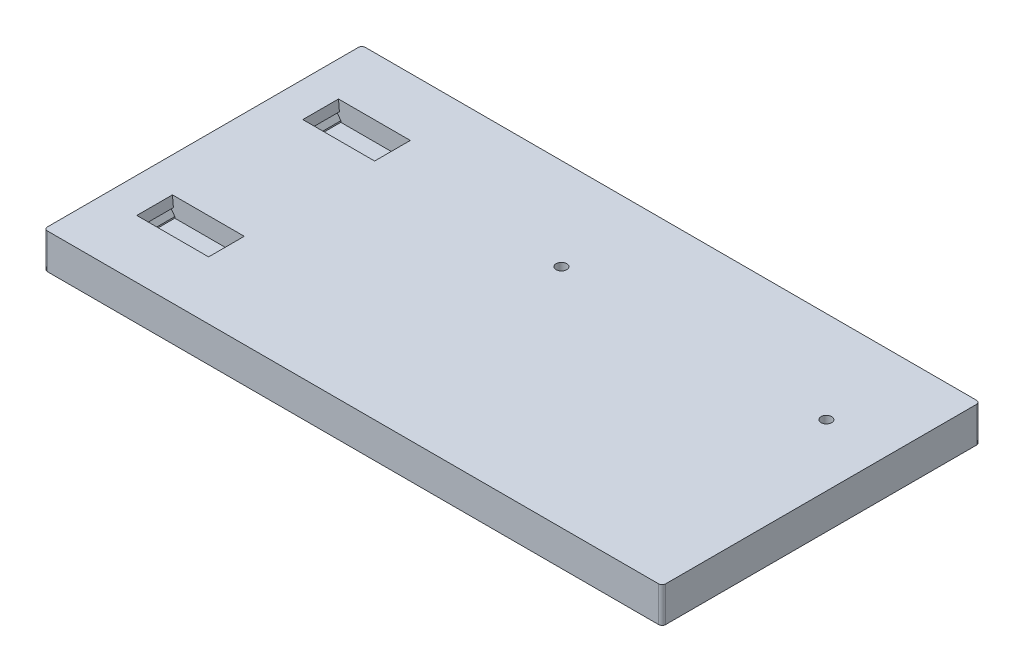
from build123d import *

# Parameters (mm, degrees)
SKETCH1_W           = 175
SKETCH1_H           = 90
BOSS_EXTRUDE1_DEPTH = 10
SKETCH2_W           = 19
SKETCH2_H           = 10.1
CUT_EXTRUDE1_DEPTH  = 5.4
CUT_EXTRUDE2_DEPTH  = 10.1
FILLET1_R           = 1
SKETCH2_8_R         = 1.5
CUT_EXTRUDE3_DEPTH  = 11


with BuildPart() as part:
    # Sketch1 → Boss-Extrude1 (new body)
    with BuildSketch(Plane(origin=(0, 0, 0), x_dir=(1, 0, 0), z_dir=(0, 1, 0))):
        Rectangle(SKETCH1_W, SKETCH1_H)
    extrude(amount=BOSS_EXTRUDE1_DEPTH)

    # Sketch2 → Cut-Extrude1 (cut)
    with BuildSketch(Plane(origin=(0, 10, 0), x_dir=(1, 0, 0), z_dir=(0, 1, 0))):
        with Locations((-67.5, -23.5)):
            Rectangle(SKETCH2_W, SKETCH2_H)
    cut_extrude1 = extrude(amount=-CUT_EXTRUDE1_DEPTH, mode=Mode.SUBTRACT)

    # Sketch7 → Cut-Extrude2 (cut)
    with BuildSketch(Plane.XY.offset(18.45)):
        Polygon((-77, 5), (-77, 10), (-77.662881067, 10), (-77.400415076, 7), (-78.400415076, 7), align=None)
        Polygon((-58, 5), (-58, 10), (-57.337118933, 10), (-57.599584924, 7), (-56.599584924, 7), align=None)
    cut_extrude2 = extrude(amount=CUT_EXTRUDE2_DEPTH, mode=Mode.SUBTRACT)

    # Mirror1: Cut-Extrude1, Cut-Extrude2 across plane
    add(cut_extrude1.mirror(Plane.XY), mode=Mode.SUBTRACT)
    add(cut_extrude2.mirror(Plane.XY), mode=Mode.SUBTRACT)

    # Fillet1
    fillet1_edges = [part.edges().sort_by_distance(p)[0] for p in [
        (-87.5, 5, -45),
        (87.5, 5, -45),
        (87.5, 5, 45),
        (-87.5, 5, 45),
    ]]
    fillet(fillet1_edges, radius=FILLET1_R)

    # Sketch2_8 → Cut-Extrude3 (cut, through all)
    with BuildSketch(Plane(origin=(0, 10, 0), x_dir=(1, 0, 0), z_dir=(0, 1, 0))):
        with Locations((-5, 19)):
            Circle(SKETCH2_8_R)
        with Locations((70, 19)):
            Circle(SKETCH2_8_R)
    extrude(amount=-CUT_EXTRUDE3_DEPTH, mode=Mode.SUBTRACT)


solid = part.part
